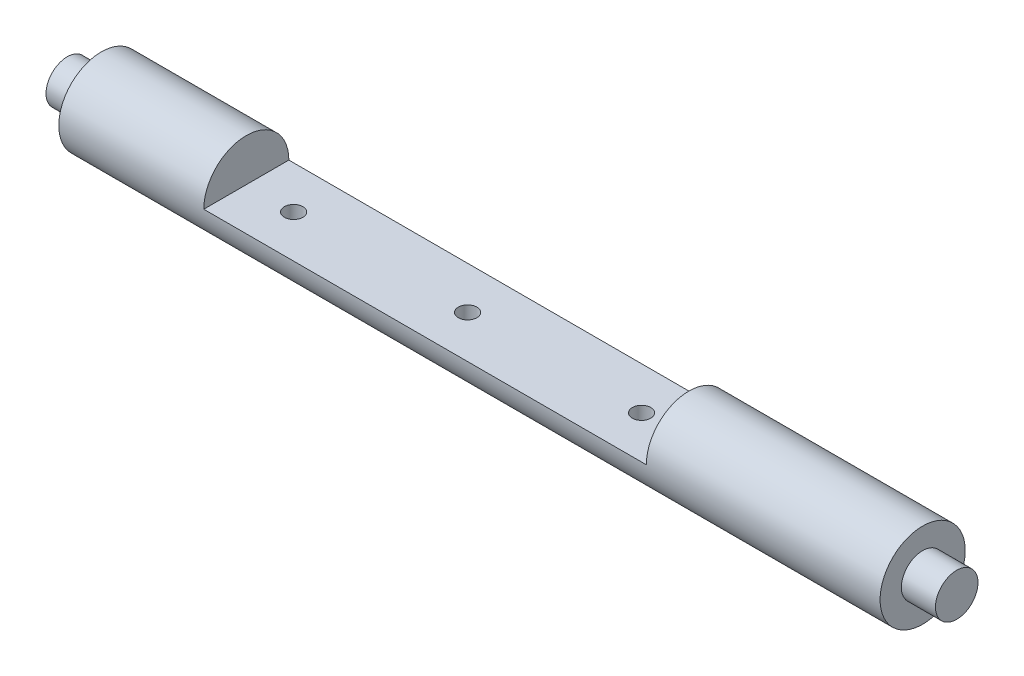
from build123d import *

# Parameters (mm, degrees)
SKETCH1_R           = 7.9375
BOSS_EXTRUDE1_DEPTH = 76.581
SKETCH3_R           = 3.96875
BOSS_EXTRUDE2_DEPTH = 6.35
SKETCH4_R           = 3.96875
BOSS_EXTRUDE3_DEPTH = 6.35
SKETCH2_W           = 82.532989992
SKETCH2_H           = 25.4
CUT_EXTRUDE1_DEPTH  = 8.9375
SKETCH5_R           = 1.7272
CUT_EXTRUDE2_DEPTH  = 8.9375


with BuildPart() as part:
    # Sketch1 → Boss-Extrude1 (new body, symmetric)
    with BuildSketch(Plane(origin=(0, 0, 0), x_dir=(0, 0, -1), z_dir=(1, 0, 0))):
        Circle(SKETCH1_R)
    extrude(amount=BOSS_EXTRUDE1_DEPTH, both=True)

    # Sketch3 → Boss-Extrude2 (add)
    with BuildSketch(Plane.ZY.offset(76.581)):
        Circle(SKETCH3_R)
    extrude(amount=BOSS_EXTRUDE2_DEPTH)

    # Sketch4 → Boss-Extrude3 (add)
    with BuildSketch(Plane(origin=(76.581, 0, 0), x_dir=(0, 0, -1), z_dir=(1, 0, 0))):
        Circle(SKETCH4_R)
    extrude(amount=BOSS_EXTRUDE3_DEPTH)

    # Sketch2 → Cut-Extrude1 (cut, through all)
    with BuildSketch(Plane(origin=(0, 0, 0), x_dir=(1, 0, 0), z_dir=(0, 1, 0))):
        with Locations((-8.279380004, 0)):
            Rectangle(SKETCH2_W, SKETCH2_H)
    extrude(amount=CUT_EXTRUDE1_DEPTH, mode=Mode.SUBTRACT)

    # Sketch5 → Cut-Extrude2 (cut, through all)
    with BuildSketch(Plane(origin=(0, 0, 0), x_dir=(1, 0, 0), z_dir=(0, 1, 0))):
        with Locations((-40.719375, 0)):
            Circle(SKETCH5_R)
        with Locations((-8.279380004, 0)):
            Circle(SKETCH5_R)
        with Locations((24.160614992, 0)):
            Circle(SKETCH5_R)
    extrude(amount=-CUT_EXTRUDE2_DEPTH, mode=Mode.SUBTRACT)


solid = part.part
